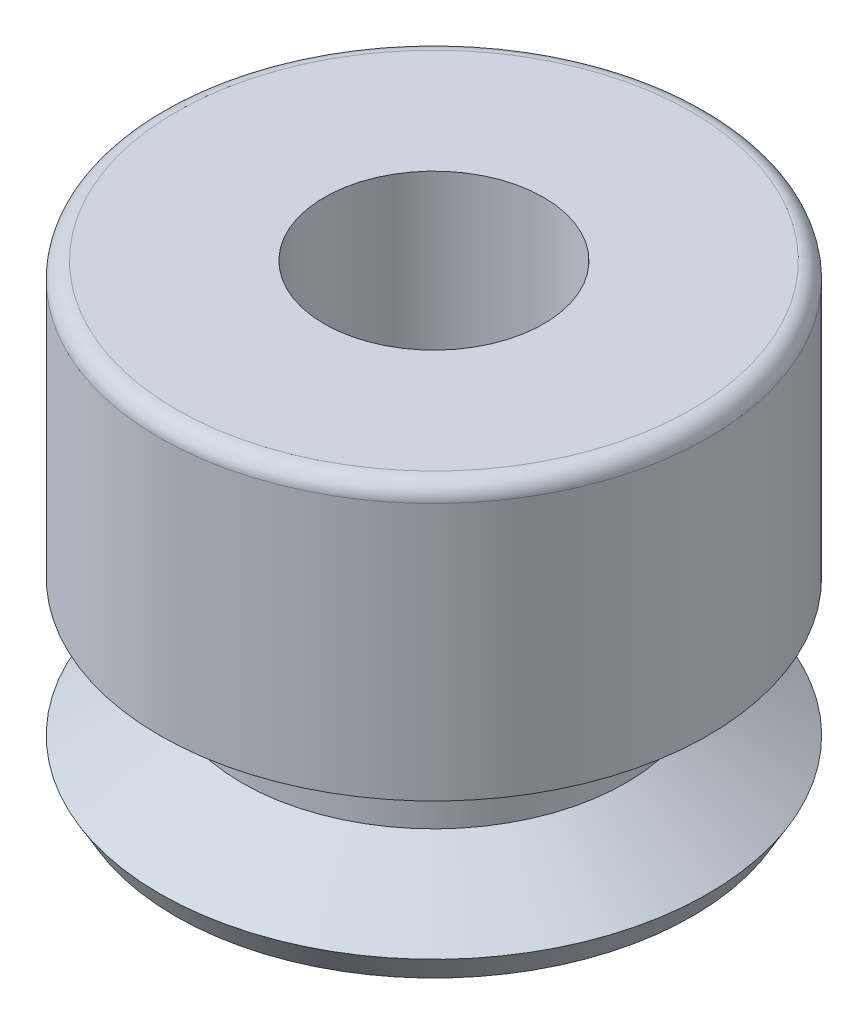
from build123d import *


with BuildPart() as part:
    # Sketch1 → Revolve1 (revolve)
    with BuildSketch(Plane.XY):
        with BuildLine():
            Line((0, 8), (4.7, 8))
            ThreePointArc((4.7, 8), (4.912132034, 7.912132034), (5, 7.7))
            Line((5, 7.7), (5, 3))
            Line((5, 3), (3.5, 2))
            Line((3.5, 2), (3.5, 1.5))
            Line((3.5, 1.5), (5, 0.5))
            Line((5, 0.5), (4.711324865, 0))
            Line((4.711324865, 0), (0, 0))
            Line((0, 0), (0, 8))
        make_face()
    revolve(axis=Axis((0, 0, 0), (0, 1, 0)))

    # Sketch2 → Cut-Revolve1 (revolve, cut)
    with BuildSketch(Plane.XY):
        Polygon((0, 8), (2, 8), (2, 5), (3, 5), (3, 1), (4.711324865, 0), (0, 0), align=None)
    revolve(axis=Axis((0, 0, 0), (0, 1, 0)), mode=Mode.SUBTRACT)


solid = part.part
